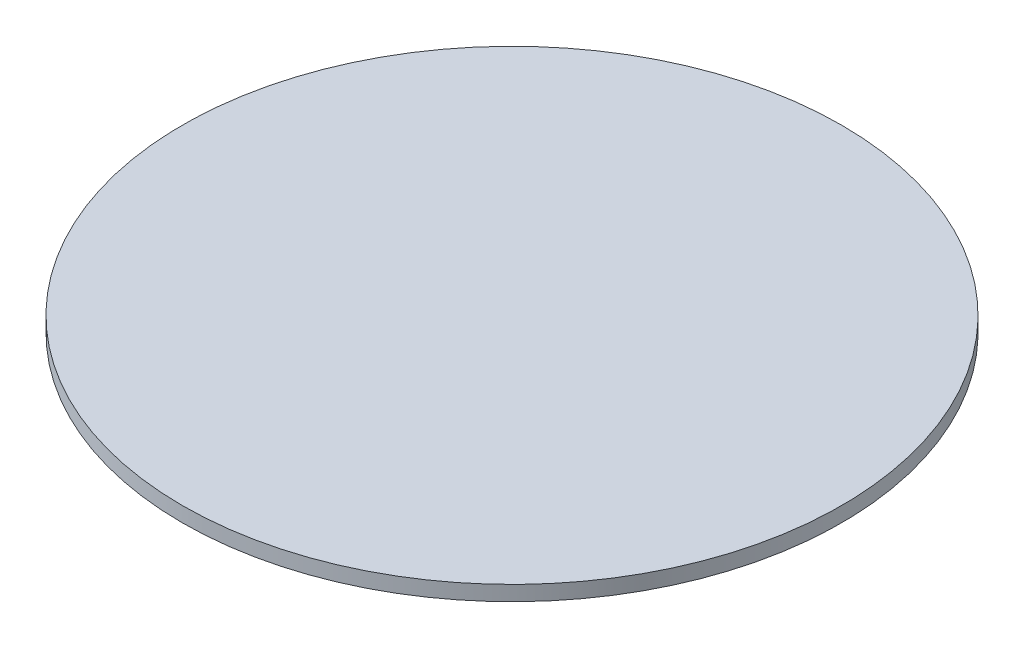
from build123d import *

# Parameters (mm, degrees)
SKETCH1_R           = 69.85
BOSS_EXTRUDE1_DEPTH = 3.175


with BuildPart() as part:
    # Sketch1 → Boss-Extrude1 (new body)
    with BuildSketch(Plane(origin=(0, 0, 0), x_dir=(1, 0, 0), z_dir=(0, 1, 0))):
        Circle(SKETCH1_R)
    extrude(amount=BOSS_EXTRUDE1_DEPTH)


solid = part.part
